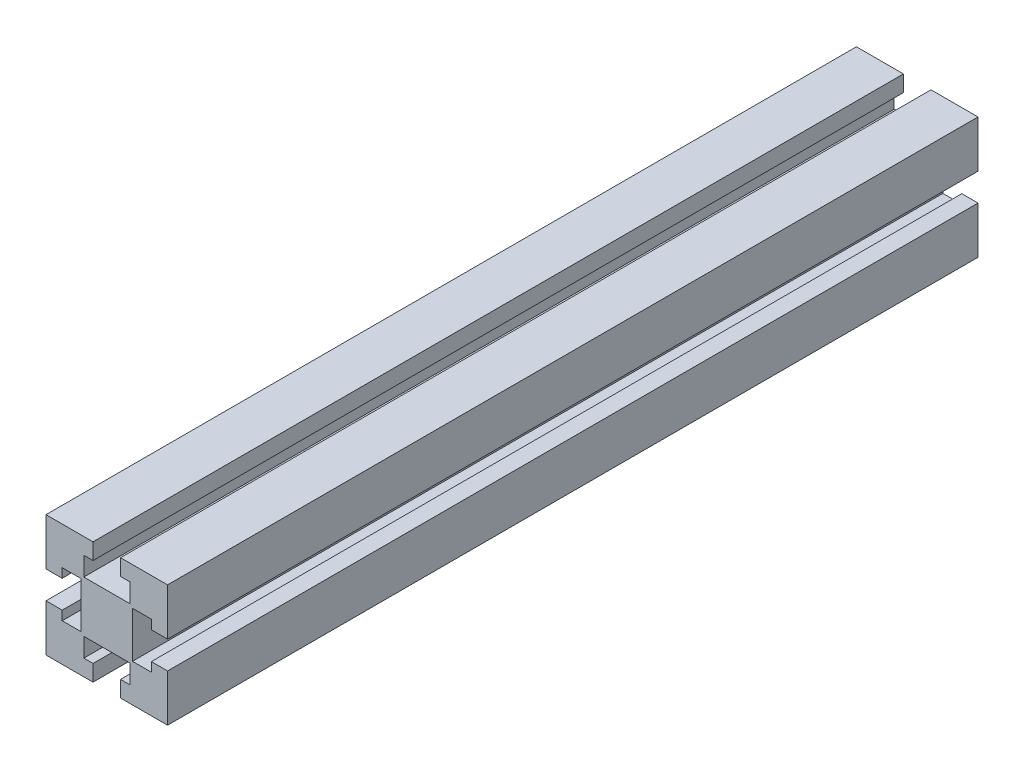
from build123d import *

# Parameters (mm, degrees)
AUFSATZ_LINEAR_AUSTRAGEN1_DEPTH = 300


with BuildPart() as part:
    # Skizze1 → Aufsatz-Linear austragen1 (new body)
    with BuildSketch(Plane.XY):
        Polygon((-18.819236164, 33.776755942), (-1.419236164, 33.776755942), (-1.419236164, 16.376755942), (-7.419236164, 16.376755942), (-7.419236164, 19.781707503), (-14.419236164, 19.781707503), (-14.419236164, 2.77180438), (-7.419236164, 2.77180438), (-7.419236164, 6.176755942), (-1.419236164, 6.176755942), (-1.419236164, -11.223244058), (-18.819236164, -11.223244058), (-18.819236164, -5.223244058), (-15.414284603, -5.223244058), (-15.414284603, 1.776755942), (-32.424187726, 1.776755942), (-32.424187726, -5.223244058), (-29.019236164, -5.223244058), (-29.019236164, -11.223244058), (-46.419236164, -11.223244058), (-46.419236164, 6.176755942), (-40.419236164, 6.176755942), (-40.419236164, 2.77180438), (-33.419236164, 2.77180438), (-33.419236164, 19.781707503), (-40.419236164, 19.781707503), (-40.419236164, 16.376755942), (-46.419236164, 16.376755942), (-46.419236164, 33.776755942), (-29.019236164, 33.776755942), (-29.019236164, 27.776755942), (-32.424187726, 27.776755942), (-32.424187726, 20.776755942), (-15.414284603, 20.776755942), (-15.414284603, 27.776755942), (-18.819236164, 27.776755942), align=None)
    extrude(amount=AUFSATZ_LINEAR_AUSTRAGEN1_DEPTH)


solid = part.part
